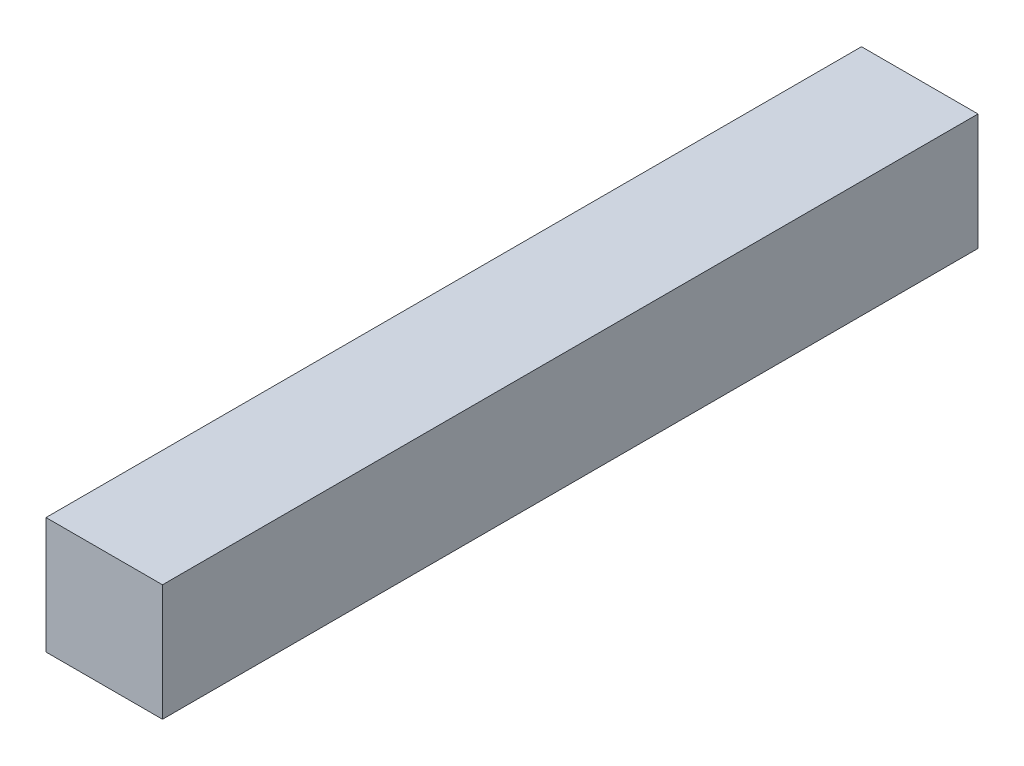
from build123d import *

# Parameters (mm, degrees)
SKETCH1_W           = 25.4
SKETCH1_H           = 25.4
BOSS_EXTRUDE1_DEPTH = 177.8


with BuildPart() as part:
    # Sketch1 → Boss-Extrude1 (new body)
    with BuildSketch(Plane.XY):
        with Locations((12.7, 12.7)):
            Rectangle(SKETCH1_W, SKETCH1_H)
    extrude(amount=BOSS_EXTRUDE1_DEPTH)


solid = part.part
